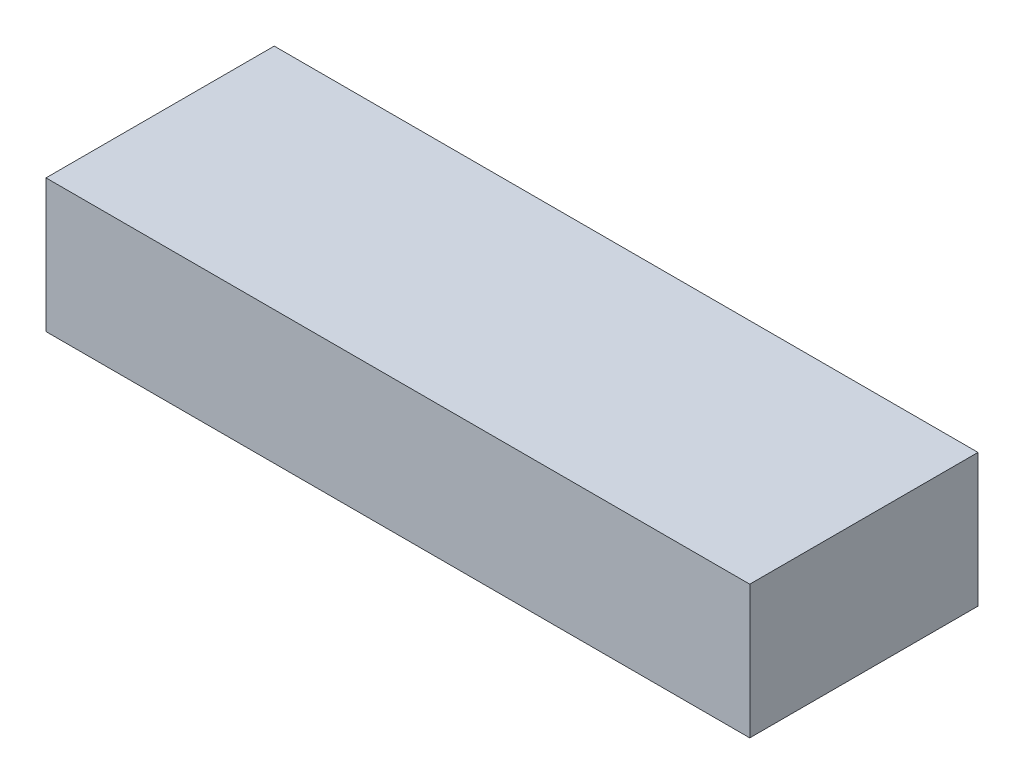
from build123d import *

# Parameters (mm, degrees)
SKETCH1_W           = 74
SKETCH1_H           = 24
BOSS_EXTRUDE1_DEPTH = 14


with BuildPart() as part:
    # Sketch1 → Boss-Extrude1 (new body)
    with BuildSketch(Plane(origin=(0, 0, 0), x_dir=(1, 0, 0), z_dir=(0, 1, 0))):
        Rectangle(SKETCH1_W, SKETCH1_H)
    extrude(amount=BOSS_EXTRUDE1_DEPTH)


solid = part.part
